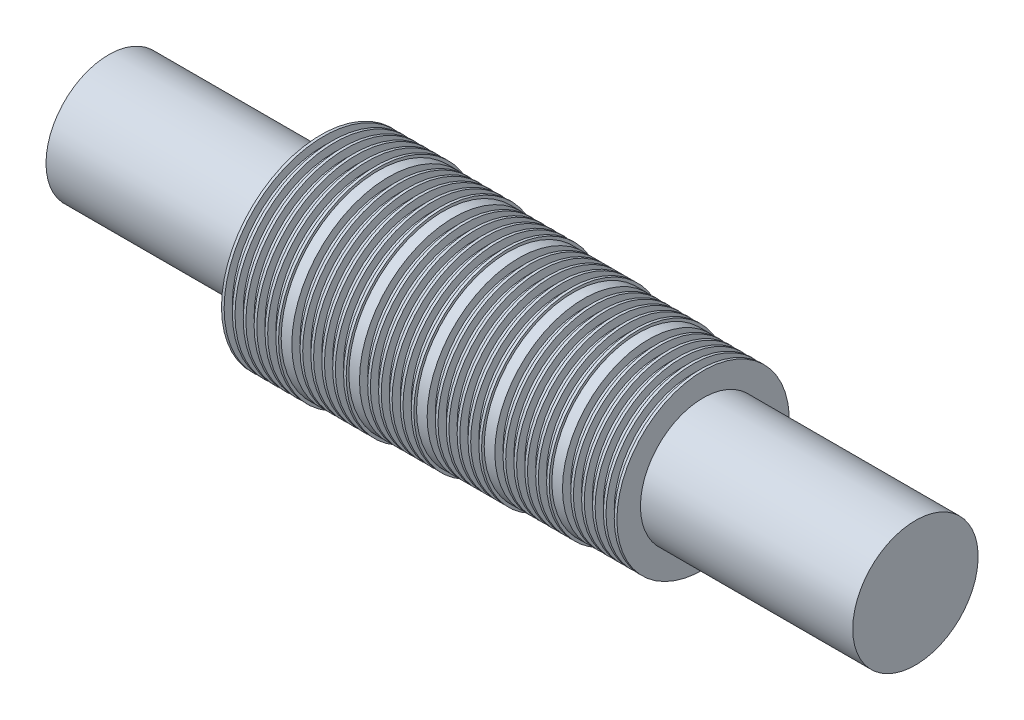
from build123d import *


with BuildPart() as part:
    # Sketch1 → Revolve1 (revolve)
    with BuildSketch(Plane.XY):
        Polygon((20.574, 9.525), (20.574, 8.7376), (21.3614, 8.7376), (21.3614, 9.525), (21.6154, 9.525), (21.6154, 8.7376), (22.4028, 8.7376), (22.4028, 9.525), (22.6568, 9.525), (22.6568, 8.7376), (23.4442, 8.7376), (23.4442, 9.525), (23.6982, 9.525), (23.6982, 8.7376), (24.4856, 8.7376), (24.4856, 9.525), (24.7396, 9.525), (24.7396, 8.7376), (25.527, 8.7376), (25.527, 9.525), (25.781, 9.525), (25.781, 9.271), (26.797, 9.271), (26.797, 8.4836), (27.5844, 8.4836), (27.5844, 9.271), (27.8384, 9.271), (27.8384, 8.4836), (28.6258, 8.4836), (28.6258, 9.271), (28.8798, 9.271), (28.8798, 8.4836), (29.6672, 8.4836), (29.6672, 9.271), (29.9212, 9.271), (29.9212, 8.4836), (30.7086, 8.4836), (30.7086, 9.271), (30.9626, 9.271), (30.9626, 8.4836), (31.75, 8.4836), (31.75, 9.271), (32.004, 9.271), (32.004, 9.017), (33.02, 9.017), (33.02, 8.2296), (33.8074, 8.2296), (33.8074, 9.017), (34.0614, 9.017), (34.0614, 8.2296), (34.8488, 8.2296), (34.8488, 9.017), (35.1028, 9.017), (35.1028, 8.2296), (35.8902, 8.2296), (35.8902, 9.017), (36.1442, 9.017), (36.1442, 8.2296), (36.9316, 8.2296), (36.9316, 9.017), (37.1856, 9.017), (37.1856, 8.2296), (37.973, 8.2296), (37.973, 9.017), (38.227, 9.017), (38.227, 8.763), (39.243, 8.763), (39.243, 7.9756), (40.0304, 7.9756), (40.0304, 8.763), (40.2844, 8.763), (40.2844, 7.9756), (41.0718, 7.9756), (41.0718, 8.763), (41.3258, 8.763), (41.3258, 7.9756), (42.1132, 7.9756), (42.1132, 8.763), (42.3672, 8.763), (42.3672, 7.9756), (43.1546, 7.9756), (43.1546, 8.763), (43.4086, 8.763), (43.4086, 7.9756), (44.196, 7.9756), (44.196, 8.763), (44.45, 8.763), (44.45, 8.509), (45.466, 8.509), (45.466, 7.7216), (46.2534, 7.7216), (46.2534, 8.509), (46.5074, 8.509), (46.5074, 7.7216), (47.2948, 7.7216), (47.2948, 8.509), (47.5488, 8.509), (47.5488, 7.7216), (48.3362, 7.7216), (48.3362, 8.509), (48.5902, 8.509), (48.5902, 7.7216), (49.3776, 7.7216), (49.3776, 8.509), (49.6316, 8.509), (49.6316, 7.7216), (50.419, 7.7216), (50.419, 8.509), (50.673, 8.509), (50.673, 8.255), (51.689, 8.255), (51.689, 7.4676), (52.4764, 7.4676), (52.4764, 8.255), (52.7304, 8.255), (52.7304, 7.4676), (53.5178, 7.4676), (53.5178, 8.255), (53.7718, 8.255), (53.7718, 7.4676), (54.5592, 7.4676), (54.5592, 8.255), (54.8132, 8.255), (54.8132, 7.4676), (55.6006, 7.4676), (55.6006, 8.255), (55.8546, 8.255), (55.8546, 7.4676), (56.642, 7.4676), (56.642, 8.255), (56.896, 8.255), (56.896, 5.999988), (77.216, 5.999988), (77.216, 0), (61.976, 0), (0, 0), (0, 5.999988), (20.32, 5.999988), (20.32, 9.525), align=None)
    revolve(axis=Axis((0, 0, 0), (1, 0, 0)))


solid = part.part
